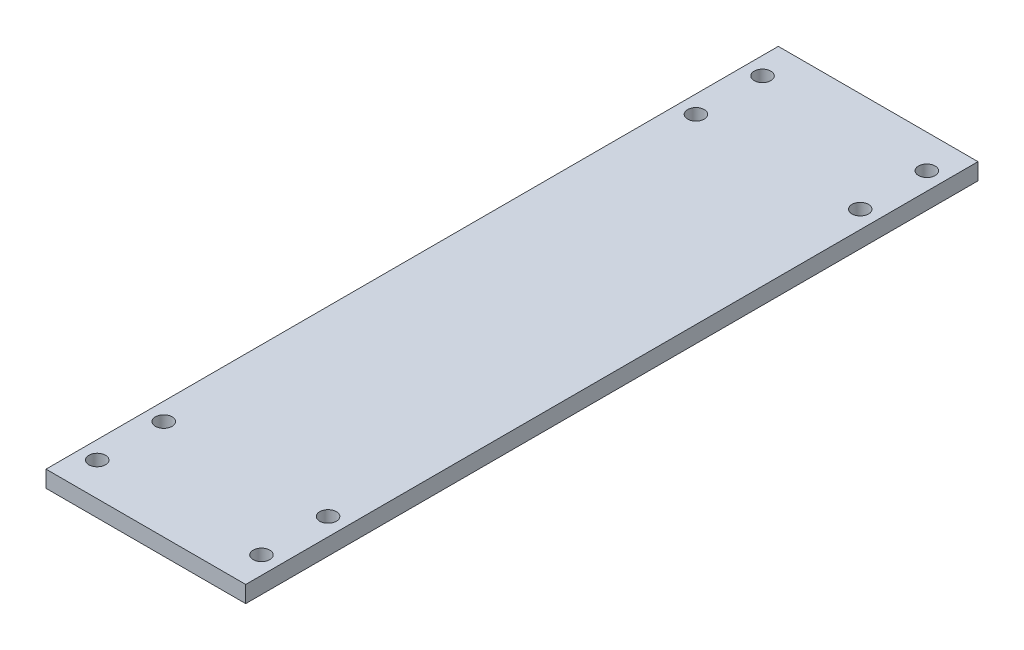
from build123d import *

# Parameters (mm, degrees)
SKETCH1_W           = 152.4
SKETCH1_H           = 558.8
BOSS_EXTRUDE1_DEPTH = 12.7
CUT_EXTRUDE1_REACH  = 14.7
SKETCH2_R           = 6.35


with BuildPart() as part:
    # Sketch1 → Boss-Extrude1 (new body)
    with BuildSketch(Plane(origin=(0, 0, 0), x_dir=(1, 0, 0), z_dir=(0, 1, 0))):
        with Locations((-76.2, -279.4)):
            Rectangle(SKETCH1_W, SKETCH1_H)
    extrude(amount=BOSS_EXTRUDE1_DEPTH)

    # Sketch2 → Cut-Extrude1 (cut, up to next)
    with BuildSketch(Plane(origin=(0, 0, 0), x_dir=(-1, 0, 0), z_dir=(0, -1, 0)), mode=Mode.PRIVATE) as cut_extrude1_sk1:
        with Locations((13.51432586, -25.547353246)):
            Circle(SKETCH2_R)
    cut_extrude1_tool1 = extrude(cut_extrude1_sk1.sketch, amount=-CUT_EXTRUDE1_REACH, mode=Mode.PRIVATE) & part.part
    add(cut_extrude1_tool1.solids().sort_by_distance((-13.514326, 0, 25.547353))[0], mode=Mode.SUBTRACT)
    # Sketch2 → Cut-Extrude1 (cut, up to next)
    with BuildSketch(Plane(origin=(0, 0, 0), x_dir=(-1, 0, 0), z_dir=(0, -1, 0)), mode=Mode.PRIVATE) as cut_extrude1_sk2:
        with Locations((13.51432586, -76.347353246)):
            Circle(SKETCH2_R)
    cut_extrude1_tool2 = extrude(cut_extrude1_sk2.sketch, amount=-CUT_EXTRUDE1_REACH, mode=Mode.PRIVATE) & part.part
    add(cut_extrude1_tool2.solids().sort_by_distance((-13.514326, 0, 76.347353))[0], mode=Mode.SUBTRACT)
    # Sketch2 → Cut-Extrude1 (cut, up to next)
    with BuildSketch(Plane(origin=(0, 0, 0), x_dir=(-1, 0, 0), z_dir=(0, -1, 0)), mode=Mode.PRIVATE) as cut_extrude1_sk3:
        with Locations((13.51432586, -482.452646754)):
            Circle(SKETCH2_R)
    cut_extrude1_tool3 = extrude(cut_extrude1_sk3.sketch, amount=-CUT_EXTRUDE1_REACH, mode=Mode.PRIVATE) & part.part
    add(cut_extrude1_tool3.solids().sort_by_distance((-13.514326, 0, 482.452647))[0], mode=Mode.SUBTRACT)
    # Sketch2 → Cut-Extrude1 (cut, up to next)
    with BuildSketch(Plane(origin=(0, 0, 0), x_dir=(-1, 0, 0), z_dir=(0, -1, 0)), mode=Mode.PRIVATE) as cut_extrude1_sk4:
        with Locations((13.51432586, -533.252646754)):
            Circle(SKETCH2_R)
    cut_extrude1_tool4 = extrude(cut_extrude1_sk4.sketch, amount=-CUT_EXTRUDE1_REACH, mode=Mode.PRIVATE) & part.part
    add(cut_extrude1_tool4.solids().sort_by_distance((-13.514326, 0, 533.252647))[0], mode=Mode.SUBTRACT)
    # Sketch2 → Cut-Extrude1 (cut, up to next)
    with BuildSketch(Plane(origin=(0, 0, 0), x_dir=(-1, 0, 0), z_dir=(0, -1, 0)), mode=Mode.PRIVATE) as cut_extrude1_sk5:
        with Locations((138.88567414, -76.347353246)):
            Circle(SKETCH2_R)
    cut_extrude1_tool5 = extrude(cut_extrude1_sk5.sketch, amount=-CUT_EXTRUDE1_REACH, mode=Mode.PRIVATE) & part.part
    add(cut_extrude1_tool5.solids().sort_by_distance((-138.885674, 0, 76.347353))[0], mode=Mode.SUBTRACT)
    # Sketch2 → Cut-Extrude1 (cut, up to next)
    with BuildSketch(Plane(origin=(0, 0, 0), x_dir=(-1, 0, 0), z_dir=(0, -1, 0)), mode=Mode.PRIVATE) as cut_extrude1_sk6:
        with Locations((138.88567414, -25.547353246)):
            Circle(SKETCH2_R)
    cut_extrude1_tool6 = extrude(cut_extrude1_sk6.sketch, amount=-CUT_EXTRUDE1_REACH, mode=Mode.PRIVATE) & part.part
    add(cut_extrude1_tool6.solids().sort_by_distance((-138.885674, 0, 25.547353))[0], mode=Mode.SUBTRACT)
    # Sketch2 → Cut-Extrude1 (cut, up to next)
    with BuildSketch(Plane(origin=(0, 0, 0), x_dir=(-1, 0, 0), z_dir=(0, -1, 0)), mode=Mode.PRIVATE) as cut_extrude1_sk7:
        with Locations((138.88567414, -482.452646754)):
            Circle(SKETCH2_R)
    cut_extrude1_tool7 = extrude(cut_extrude1_sk7.sketch, amount=-CUT_EXTRUDE1_REACH, mode=Mode.PRIVATE) & part.part
    add(cut_extrude1_tool7.solids().sort_by_distance((-138.885674, 0, 482.452647))[0], mode=Mode.SUBTRACT)
    # Sketch2 → Cut-Extrude1 (cut, up to next)
    with BuildSketch(Plane(origin=(0, 0, 0), x_dir=(-1, 0, 0), z_dir=(0, -1, 0)), mode=Mode.PRIVATE) as cut_extrude1_sk8:
        with Locations((138.88567414, -533.252646754)):
            Circle(SKETCH2_R)
    cut_extrude1_tool8 = extrude(cut_extrude1_sk8.sketch, amount=-CUT_EXTRUDE1_REACH, mode=Mode.PRIVATE) & part.part
    add(cut_extrude1_tool8.solids().sort_by_distance((-138.885674, 0, 533.252647))[0], mode=Mode.SUBTRACT)


solid = part.part
